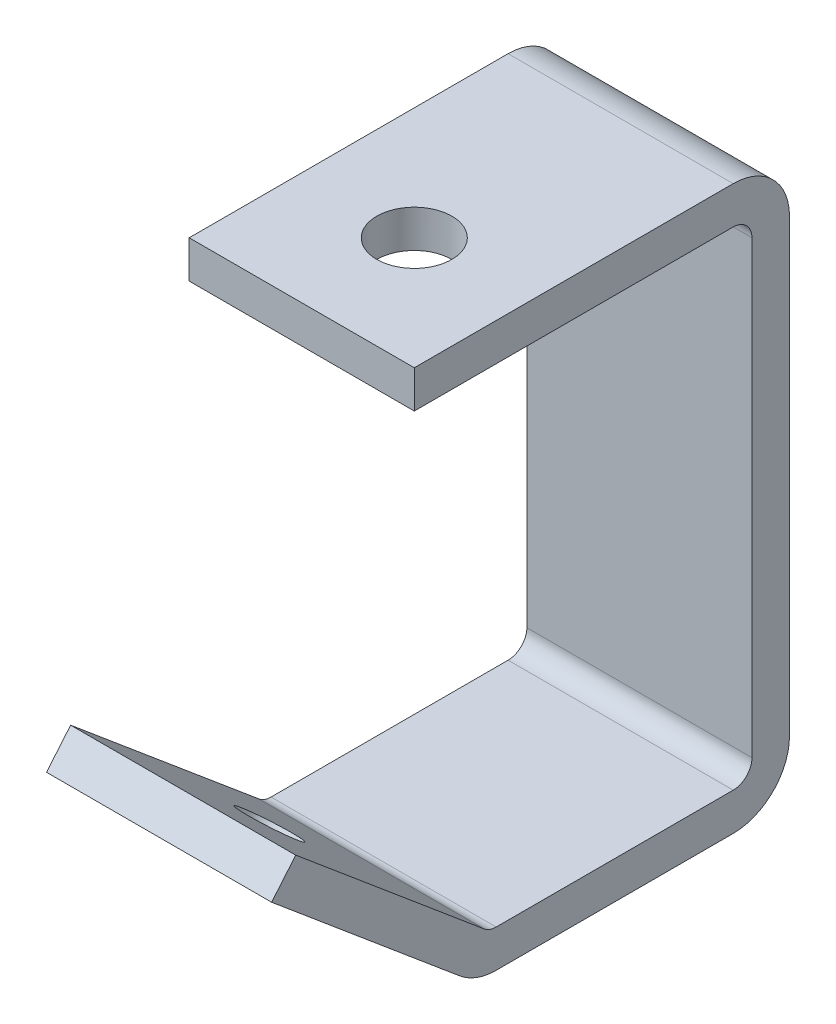
from build123d import *

# Parameters (mm, degrees)
BASE_EXTRUDE_THIN_DEPTH = 19.05
CUT_EXTRUDE1_REACH      = 97.25
SKETCH2_R               = 6.35
SKETCH3_R               = 4.7625
CUT_EXTRUDE2_DEPTH      = 29.549935702


with BuildPart() as part:
    # Sketch1 → Base-Extrude-Thin (new body, symmetric)
    with BuildSketch(Plane(origin=(0, 0, 0), x_dir=(0, 0, -1), z_dir=(1, 0, 0))):
        with BuildLine():
            Line((-77.216478592, 27.494340102), (-45.335245167, 0.742808893))
            ThreePointArc((-45.335245167, 0.742808893), (-44.380308461, 0.191475929), (-43.294394506, 0))
            Line((-43.294394506, 0), (-3.175, 0))
            ThreePointArc((-3.175, 0), (-0.92993597, 0.92993597), (0, 3.175))
            Line((0, 3.175), (0, 79.375))
            ThreePointArc((0, 79.375), (-0.92993597, 81.62006403), (-3.175, 82.55))
            Line((-3.175, 82.55), (-57.15, 82.55))
            Line((-57.15, 82.55), (-57.15, 88.9))
            Line((-57.15, 88.9), (-3.175, 88.9))
            ThreePointArc((-3.175, 88.9), (3.560192091, 86.110192091), (6.35, 79.375))
            Line((6.35, 79.375), (6.35, 3.175))
            ThreePointArc((6.35, 3.175), (3.560192091, -3.560192091), (-3.175, -6.35))
            Line((-3.175, -6.35), (-43.294394506, -6.35))
            ThreePointArc((-43.294394506, -6.35), (-46.552136371, -5.775572213), (-49.416946488, -4.121573321))
            Line((-49.416946488, -4.121573321), (-81.298179914, 22.629957888))
            Line((-81.298179914, 22.629957888), (-77.216478592, 27.494340102))
        make_face()
    extrude(amount=BASE_EXTRUDE_THIN_DEPTH, both=True)

    # Sketch2 → Cut-Extrude1 (cut, up to next)
    with BuildSketch(Plane(origin=(0, 88.9, 0), x_dir=(-1, 0, 0), z_dir=(0, 1, 0)), mode=Mode.PRIVATE) as cut_extrude1_sk1:
        with Locations((0, 38.1)):
            Circle(SKETCH2_R)
    cut_extrude1_tool1 = extrude(cut_extrude1_sk1.sketch, amount=-CUT_EXTRUDE1_REACH, mode=Mode.PRIVATE) & part.part
    add(cut_extrude1_tool1.solids().sort_by_distance((0, 88.9, 38.1))[0], mode=Mode.SUBTRACT)

    # Sketch3 → Cut-Extrude2 (cut, through all)
    with BuildSketch(Plane(origin=(0, -21.887352311, 18.365669251), x_dir=(1, 0, 0), z_dir=(0, 0.766044443, -0.64278761))):
        with Locations((0, -57.758202533)):
            Circle(SKETCH3_R)
    extrude(amount=-CUT_EXTRUDE2_DEPTH, mode=Mode.SUBTRACT)


solid = part.part
